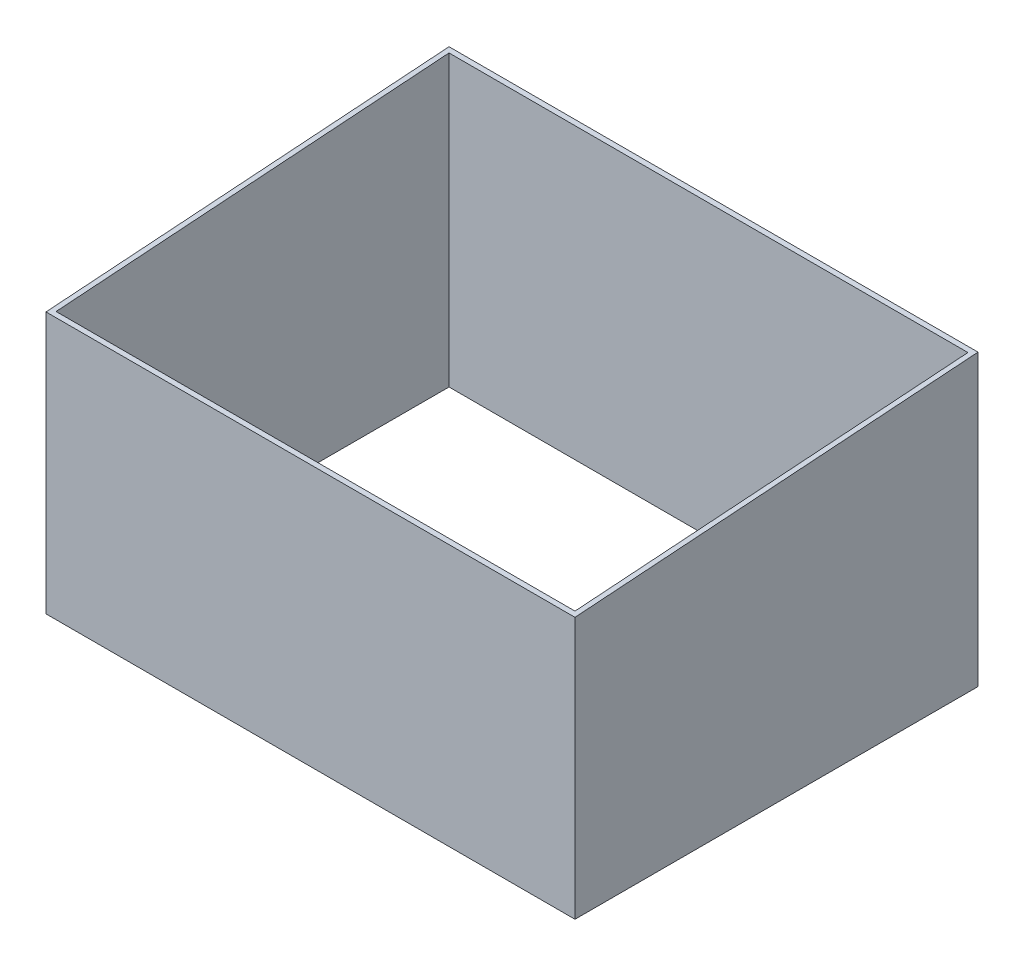
from build123d import *

# Parameters (mm, degrees)
SKETCH_1_W          = 4200
SKETCH_1_H          = 3200
SKETCH_1_W_2        = 4120
SKETCH_1_H_2        = 3120
EXTRUDE_1_DEPTH     = 2300
SKETCH_2_OUTSIDE_W  = 4353.868
SKETCH_2_OUTSIDE_H  = 3453.868
CUT_EXTRUDE_1_DEPTH = 4201


with BuildPart() as part:
    # Эскиз1 → Вытянуть-Тонкостенный1 (new body)
    with BuildSketch(Plane(origin=(0, 0, 0), x_dir=(1, 0, 0), z_dir=(0, 1, 0))):
        with Locations((2100, 1600)):
            Rectangle(SKETCH_1_W, SKETCH_1_H)
        with Locations((2100, 1600)):
            Rectangle(SKETCH_1_W_2, SKETCH_1_H_2, mode=Mode.SUBTRACT)
    extrude(amount=EXTRUDE_1_DEPTH)

    # Эскиз2 outside → Вырез-Вытянуть1 (cut, through all)
    with BuildSketch(Plane.ZY):
        with Locations((-1600, 1150)):
            Rectangle(SKETCH_2_OUTSIDE_W, SKETCH_2_OUTSIDE_H)
        Polygon((-3200, 2300), (0, 2076.446830349), (0, 0), (-3200, 0), align=None, mode=Mode.SUBTRACT)
    extrude(amount=-CUT_EXTRUDE_1_DEPTH, mode=Mode.SUBTRACT)


solid = part.part
